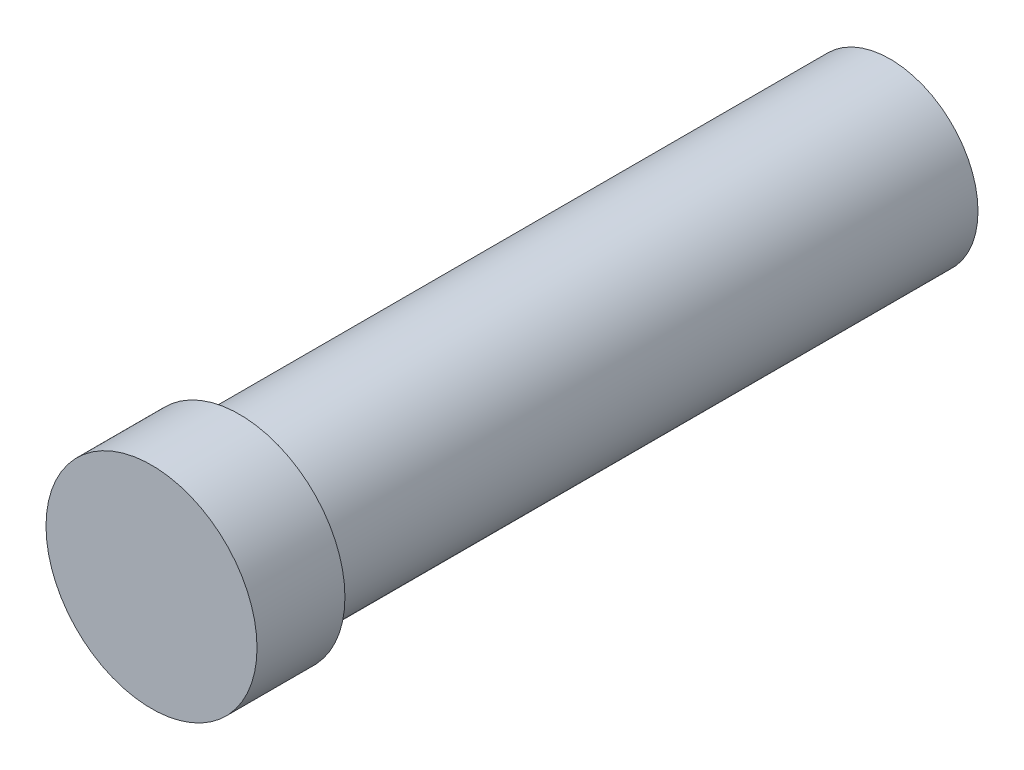
from build123d import *

# Parameters (mm, degrees)
SKETCH1_R           = 5
BOSS_EXTRUDE1_DEPTH = 37
SKETCH2_R           = 6
BOSS_EXTRUDE2_DEPTH = 5


with BuildPart() as part:
    # Sketch1 → Boss-Extrude1 (new body)
    with BuildSketch(Plane.XY):
        Circle(SKETCH1_R)
    extrude(amount=BOSS_EXTRUDE1_DEPTH)

    # Sketch2 → Boss-Extrude2 (add)
    with BuildSketch(Plane.XY.offset(37)):
        Circle(SKETCH2_R)
    extrude(amount=BOSS_EXTRUDE2_DEPTH)


solid = part.part
